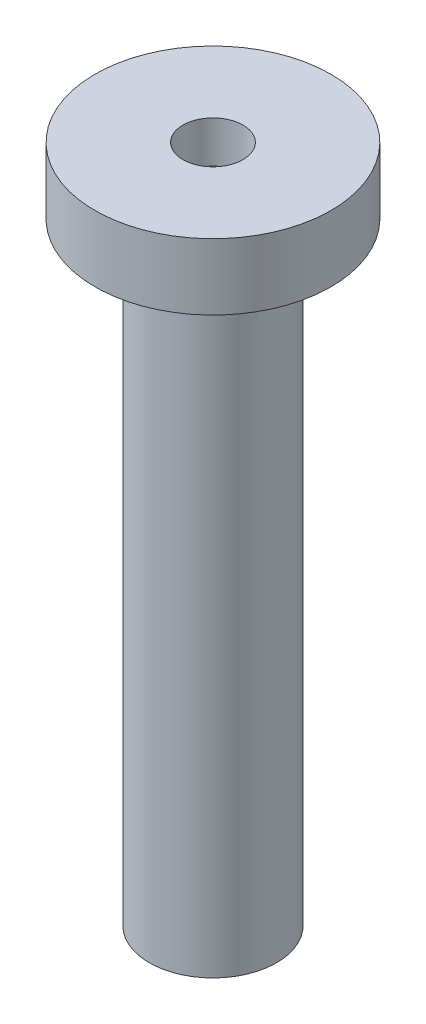
from build123d import *


with BuildPart() as part:
    # Sketch2 → Revolve1 (revolve)
    with BuildSketch(Plane.XY):
        Polygon((0, 0), (1.3, 0), (1.3, 12.5), (2.408609151, 12.5), (2.408609151, 13.850023297), (0.612219447, 13.850023297), (0.612219447, 12.997556671), (0, 12.5), align=None)
    revolve(axis=Axis((0, 0, 0), (0, 1, 0)))


solid = part.part
